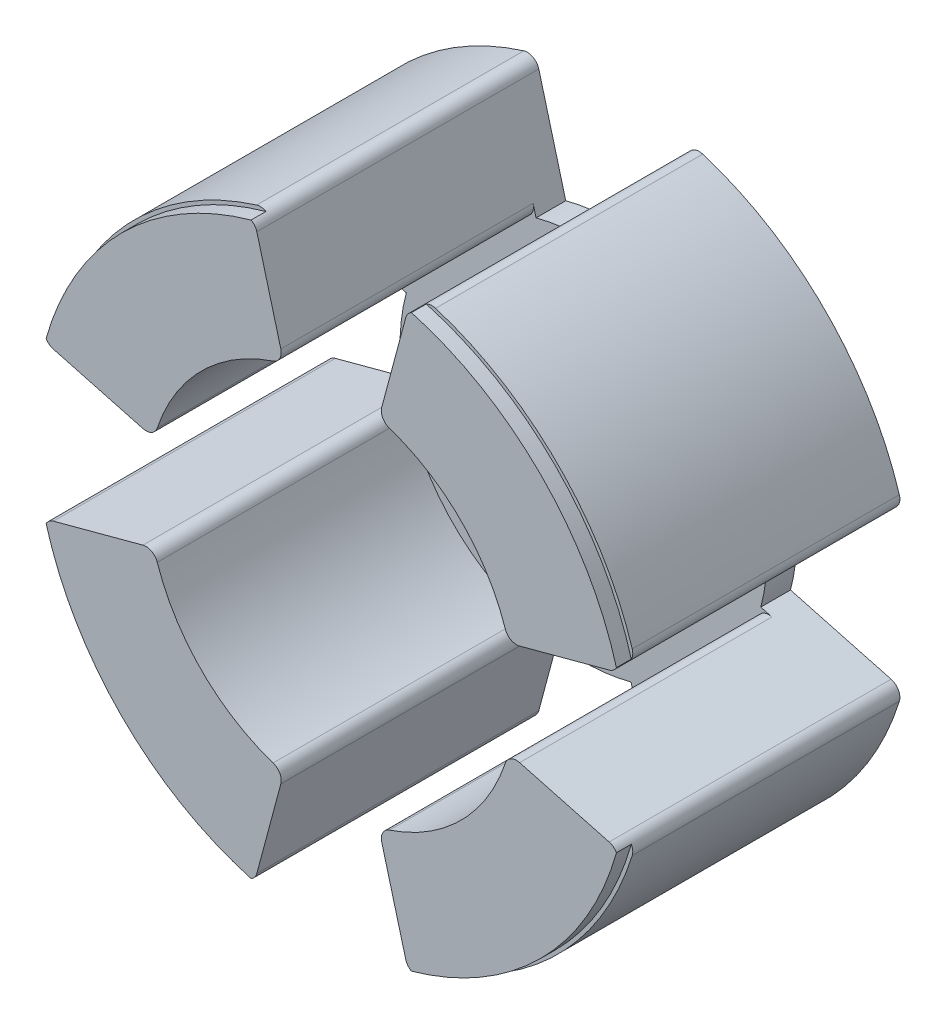
from build123d import *

# Parameters (mm, degrees)
SKETCH2_R                = 64.135
BOSS_EXTRUDE1_DEPTH      = 6.35
SKETCH3_R                = 64.135
SKETCH3_R_2              = 39.2557
BOSS_EXTRUDE2_DEPTH      = 50.8
SKETCH4_R                = 63.373
SKETCH4_R_2              = 39.2557
BOSS_EXTRUDE3_DEPTH      = 3.175
CUT_EXTRUDE1_DEPTH       = 61.325
FILLET1_R                = 2.54
CIRPATTERN1_COUNT        = 4
FILLET1_OF_CIRPATTERN1_R = 2.54


with BuildPart() as part:
    # Sketch2 → Boss-Extrude1 (new body)
    with BuildSketch(Plane.XY):
        Circle(SKETCH2_R)
    extrude(amount=BOSS_EXTRUDE1_DEPTH)

    # Sketch3 → Boss-Extrude2 (add)
    with BuildSketch(Plane.XY.offset(6.35)):
        Circle(SKETCH3_R)
        Circle(SKETCH3_R_2, mode=Mode.SUBTRACT)
    extrude(amount=BOSS_EXTRUDE2_DEPTH)

    # Sketch4 → Boss-Extrude3 (add)
    with BuildSketch(Plane.XY.offset(57.15)):
        Circle(SKETCH4_R)
        Circle(SKETCH4_R_2, mode=Mode.SUBTRACT)
    extrude(amount=BOSS_EXTRUDE3_DEPTH)

    # Sketch5 → Cut-Extrude1 (cut, through all)
    with BuildSketch(Plane.XY.offset(60.325)):
        with BuildLine():
            Line((-10.160122789, 37.918094459), (-16.599359458, 61.949652869))
            ThreePointArc((-16.599359458, 61.949652869), (0, 64.135), (16.599359458, 61.949652869))
            Line((16.599359458, 61.949652869), (10.160122789, 37.918094459))
            ThreePointArc((10.160122789, 37.918094459), (0, 39.2557), (-10.160122789, 37.918094459))
        make_face()
    cut_extrude1 = extrude(amount=-CUT_EXTRUDE1_DEPTH, mode=Mode.SUBTRACT)

    # Fillet1
    fillet1_edges = [part.edges().sort_by_distance(p)[0] for p in [
        (16.599359458, 61.949652869, 28.575),
        (10.160122789, 37.918094459, 33.3375),
        (-10.160122789, 37.918094459, 33.3375),
        (-16.599359458, 61.949652869, 28.575),
    ]]
    fillet(fillet1_edges, radius=FILLET1_R)

    # CirPattern1: Cut-Extrude1 ×4 about axis
    cirpattern1_axis = Axis((0, 0, 0), (0, 0, 1))
    for i in range(1, CIRPATTERN1_COUNT):
        add(cut_extrude1.rotate(cirpattern1_axis, i * 360 / CIRPATTERN1_COUNT), mode=Mode.SUBTRACT)

    # Fillet1 of CirPattern1
    fillet1_of_cirpattern1_edges = [part.edges().sort_by_distance(p)[0] for p in [
        (-61.949652869, 16.599359458, 28.575),
        (-37.918094459, 10.160122789, 33.3375),
        (-37.918094459, -10.160122789, 33.3375),
        (-61.949652869, -16.599359458, 28.575),
        (-16.599359458, -61.949652869, 28.575),
        (-10.160122789, -37.918094459, 33.3375),
        (10.160122789, -37.918094459, 33.3375),
        (16.599359458, -61.949652869, 28.575),
        (61.949652869, -16.599359458, 28.575),
        (37.918094459, -10.160122789, 33.3375),
        (37.918094459, 10.160122789, 33.3375),
        (61.949652869, 16.599359458, 28.575),
    ]]
    fillet(fillet1_of_cirpattern1_edges, radius=FILLET1_OF_CIRPATTERN1_R)


solid = part.part
